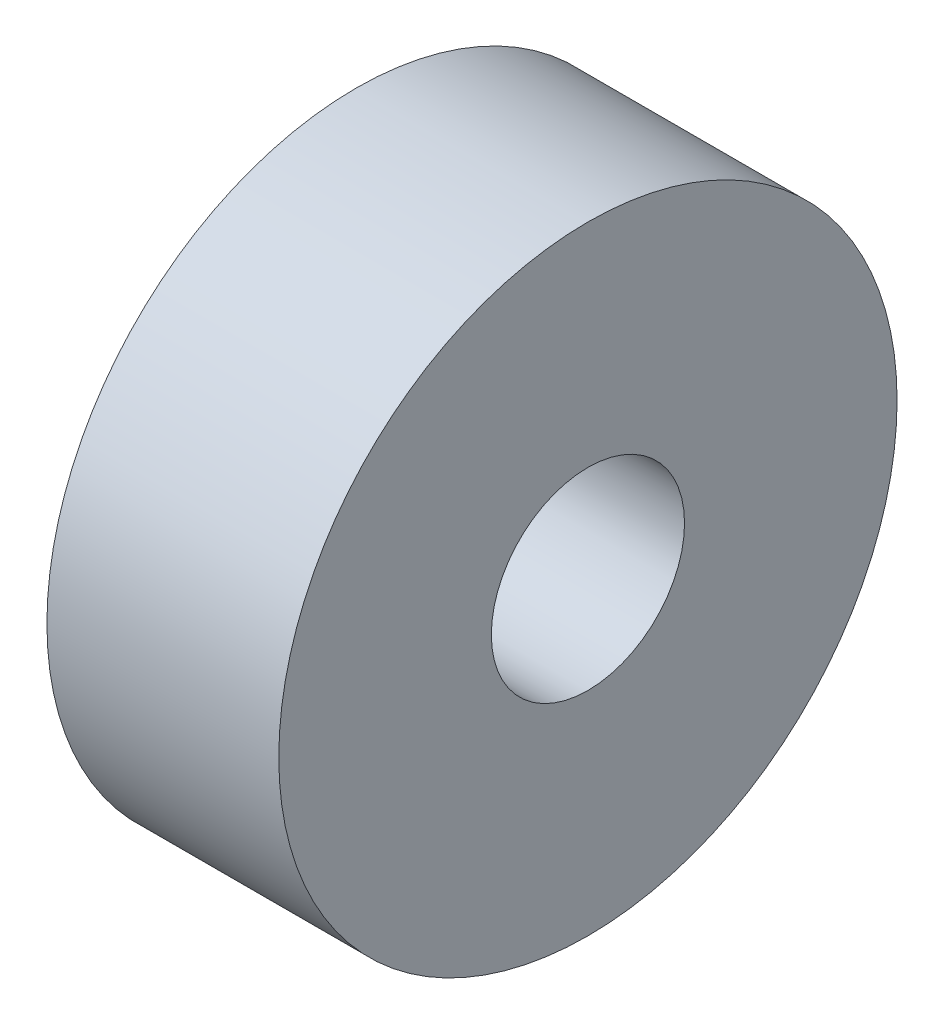
from build123d import *

# Parameters (mm, degrees)
SKETCH1_R           = 4
SKETCH1_R_2         = 1.25
BOSS_EXTRUDE1_DEPTH = 3


with BuildPart() as part:
    # Sketch1 → Boss-Extrude1 (new body)
    with BuildSketch(Plane(origin=(0, 0, 0), x_dir=(0, 0, -1), z_dir=(1, 0, 0))):
        Circle(SKETCH1_R)
        Circle(SKETCH1_R_2, mode=Mode.SUBTRACT)
    extrude(amount=BOSS_EXTRUDE1_DEPTH)


solid = part.part
